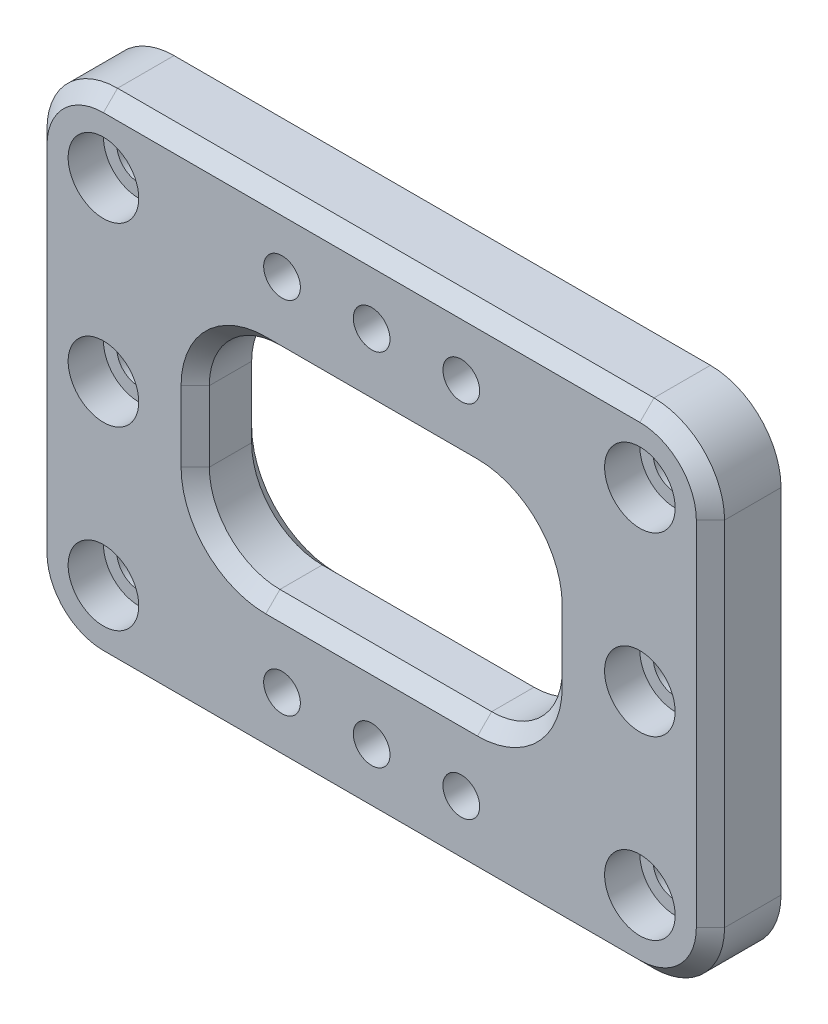
from build123d import *

# Parameters (mm, degrees)
SKETCH_1_W          = 96
SKETCH_1_H          = 70
EXTRUDE_1_DEPTH     = 10
FILLET_1_R          = 10
SKETCH_2_R          = 2.6
CUT_EXTRUDE_1_DEPTH = 10
SKETCH_3_R          = 5
CUT_EXTRUDE_2_DEPTH = 5
SKETCH_4_R          = 3.1
CUT_EXTRUDE_3_DEPTH = 5
CHAMFER_1_SIZE      = 1
CHAMFER_2_SIZE      = 2
SKETCH_5_W          = 50
SKETCH_5_H          = 30
CUT_EXTRUDE_4_DEPTH = 10
FILLET_2_R          = 10
CHAMFER_3_SIZE      = 2


with BuildPart() as part:
    # 草图1 → 凸台-拉伸1 (new body)
    with BuildSketch(Plane.XY):
        Rectangle(SKETCH_1_W, SKETCH_1_H)
    extrude(amount=EXTRUDE_1_DEPTH)

    # 圆角1
    fillet_1_edges = [part.edges().sort_by_distance(p)[0] for p in [
        (48, -35, 5),
        (-48, -35, 5),
        (-48, 35, 5),
        (48, 35, 5),
    ]]
    fillet(fillet_1_edges, radius=FILLET_1_R)

    # 草图2 → 切除-拉伸1 (cut)
    with BuildSketch(Plane.XY.offset(10)):
        with Locations((0, 25.5)):
            Circle(SKETCH_2_R)
        with Locations((-12.7, 25.5)):
            Circle(SKETCH_2_R)
        with Locations((12.7, 25.5)):
            Circle(SKETCH_2_R)
        with Locations((-12.7, -25.5)):
            Circle(SKETCH_2_R)
        with Locations((0, -25.5)):
            Circle(SKETCH_2_R)
        with Locations((12.7, -25.5)):
            Circle(SKETCH_2_R)
    extrude(amount=-CUT_EXTRUDE_1_DEPTH, mode=Mode.SUBTRACT)

    # 草图3 → 切除-拉伸2 (cut)
    with BuildSketch(Plane.XY.offset(10)):
        with Locations((-38, 25)):
            Circle(SKETCH_3_R)
        with Locations((-38, 0)):
            Circle(SKETCH_3_R)
        with Locations((-38, -25)):
            Circle(SKETCH_3_R)
        with Locations((38, -25)):
            Circle(SKETCH_3_R)
        with Locations((38, 0)):
            Circle(SKETCH_3_R)
        with Locations((38, 25)):
            Circle(SKETCH_3_R)
    extrude(amount=-CUT_EXTRUDE_2_DEPTH, mode=Mode.SUBTRACT)

    # 草图4 → 切除-拉伸3 (cut)
    with BuildSketch(Plane.XY.offset(5)):
        with Locations((-38, 25)):
            Circle(SKETCH_4_R)
        with Locations((-38, 0)):
            Circle(SKETCH_4_R)
        with Locations((-38, -25)):
            Circle(SKETCH_4_R)
        with Locations((38, 25)):
            Circle(SKETCH_4_R)
        with Locations((38, 0)):
            Circle(SKETCH_4_R)
        with Locations((38, -25)):
            Circle(SKETCH_4_R)
    extrude(amount=-CUT_EXTRUDE_3_DEPTH, mode=Mode.SUBTRACT)

    # 倒角1
    chamfer_1_edges = [part.edges().sort_by_distance(p)[0] for p in [
        (34.9, 0, 0),
        (34.9, -25, 0),
        (-41.1, 25, 0),
        (-41.1, 0, 0),
        (-41.1, -25, 0),
        (34.9, 25, 0),
    ]]
    chamfer(chamfer_1_edges, length=CHAMFER_1_SIZE)

    # 倒角2
    chamfer_2_edges = [part.edges().sort_by_distance(p)[0] for p in [
        (0, 35, 10),
        (48, 0, 10),
        (-48, 0, 10),
        (0, -35, 10),
        (-45.071067812, -32.071067812, 10),
        (45.071067812, -32.071067812, 10),
        (-45.071067812, 32.071067812, 10),
        (45.071067812, 32.071067812, 10),
    ]]
    chamfer(chamfer_2_edges, length=CHAMFER_2_SIZE)

    # 草图5 → 切除-拉伸4 (cut)
    with BuildSketch(Plane.XY.offset(10)):
        Rectangle(SKETCH_5_W, SKETCH_5_H)
    extrude(amount=-CUT_EXTRUDE_4_DEPTH, mode=Mode.SUBTRACT)

    # 圆角2
    fillet_2_edges = [part.edges().sort_by_distance(p)[0] for p in [
        (25, 15, 5),
        (25, -15, 5),
        (-25, -15, 5),
        (-25, 15, 5),
    ]]
    fillet(fillet_2_edges, radius=FILLET_2_R)

    # 倒角3
    chamfer_3_edges = [part.edges().sort_by_distance(p)[0] for p in [
        (25, 0, 10),
        (25, 0, 0),
        (0, -15, 10),
        (0, -15, 0),
        (0, 15, 10),
        (0, 15, 0),
        (-25, 0, 10),
        (-25, 0, 0),
        (22.071067812, -12.071067812, 10),
        (22.071067812, -12.071067812, 0),
        (22.071067812, 12.071067812, 10),
        (22.071067812, 12.071067812, 0),
        (-22.071067812, -12.071067812, 10),
        (-22.071067812, -12.071067812, 0),
        (-22.071067812, 12.071067812, 10),
        (-22.071067812, 12.071067812, 0),
    ]]
    chamfer(chamfer_3_edges, length=CHAMFER_3_SIZE)


solid = part.part
